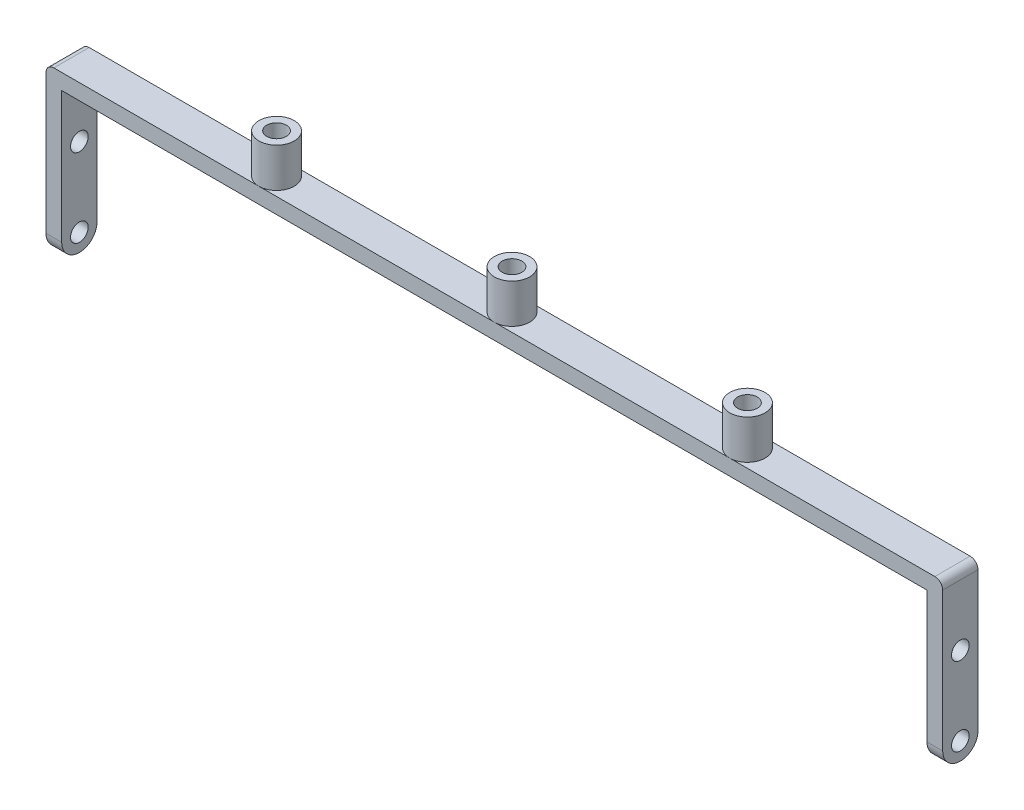
from build123d import *

# Parameters (mm, degrees)
BOSS_EXTRUDE1_DEPTH = 9
SKETCH2_R           = 2.25
CUT_EXTRUDE1_DEPTH  = 229.5
FILLET1_R           = 2
SKETCH3_R           = 4.5
SKETCH3_R_2         = 2.5
BOSS_EXTRUDE2_DEPTH = 10


with BuildPart() as part:
    # Sketch1 → Boss-Extrude1 (new body)
    with BuildSketch(Plane.XY):
        Polygon((-110.25, 0), (110.25, 0), (110.25, -38), (114.25, -38), (114.25, 4), (-114.25, 4), (-114.25, -38), (-110.25, -38), align=None)
    extrude(amount=BOSS_EXTRUDE1_DEPTH)

    # Sketch2 → Cut-Extrude1 (cut, through all)
    with BuildSketch(Plane(origin=(114.25, 0, 0), x_dir=(0, 0, -1), z_dir=(1, 0, 0))):
        with Locations((-4.5, -13.5)):
            Circle(SKETCH2_R)
        with BuildLine():
            ThreePointArc((-4.5, -38), (-7.681980515, -36.681980515), (-9, -33.5))
            Line((-9, -33.5), (-9, -38))
            Line((-9, -38), (-4.5, -38))
        make_face()
        with BuildLine():
            Line((0, -38), (0, -33.5))
            ThreePointArc((0, -33.5), (-1.318019485, -36.681980515), (-4.5, -38))
            Line((-4.5, -38), (0, -38))
        make_face()
        with Locations((-4.5, -33.5)):
            Circle(SKETCH2_R)
    extrude(amount=-CUT_EXTRUDE1_DEPTH, mode=Mode.SUBTRACT)

    # Fillet1
    fillet1_edges = [part.edges().sort_by_distance(p)[0] for p in [
        (114.25, 4, 4.5),
        (-114.25, 4, 4.5),
    ]]
    fillet(fillet1_edges, radius=FILLET1_R)

    # Sketch3 → Boss-Extrude2 (add)
    with BuildSketch(Plane(origin=(0, 4, 0), x_dir=(1, 0, 0), z_dir=(0, 1, 0))):
        with Locations((0, -4.5)):
            Circle(SKETCH3_R)
        with Locations((0, -4.5)):
            Circle(SKETCH3_R_2, mode=Mode.SUBTRACT)
        with Locations((60, -4.5)):
            Circle(SKETCH3_R)
        with Locations((60, -4.5)):
            Circle(SKETCH3_R_2, mode=Mode.SUBTRACT)
        with Locations((-60, -4.5)):
            Circle(SKETCH3_R)
        with Locations((-60, -4.5)):
            Circle(SKETCH3_R_2, mode=Mode.SUBTRACT)
    extrude(amount=BOSS_EXTRUDE2_DEPTH)


solid = part.part
